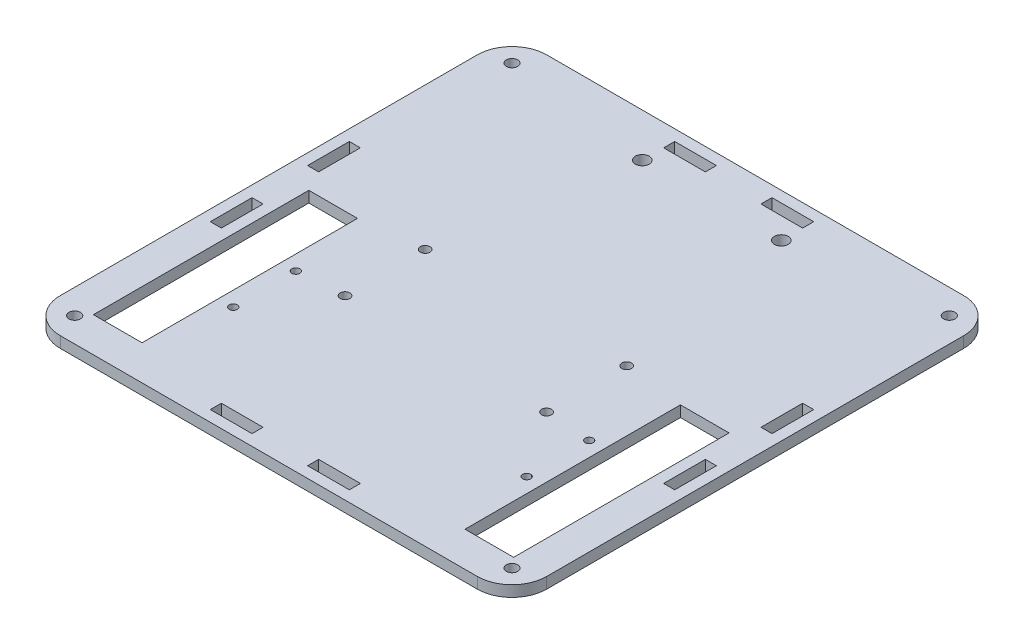
from build123d import *

# Parameters (mm, degrees)
SKETCH1_W           = 140
SKETCH1_H           = 140
SKETCH1_R           = 1.4
SKETCH1_R_2         = 1.15
SKETCH1_R_3         = 2
SKETCH1_R_4         = 1.65
SKETCH1_W_2         = 14
SKETCH1_H_2         = 62
SKETCH1_W_3         = 3.175
SKETCH1_H_3         = 12
SKETCH1_W_4         = 12
SKETCH1_H_4         = 3.175
BOSS_EXTRUDE1_DEPTH = 3.175
FILLET1_R           = 10


with BuildPart() as part:
    # Sketch1 → Boss-Extrude1 (new body)
    with BuildSketch(Plane(origin=(0, 0, 0), x_dir=(1, 0, 0), z_dir=(0, 1, 0))):
        Rectangle(SKETCH1_W, SKETCH1_H)
        with Locations((29, 4)):
            Circle(SKETCH1_R, mode=Mode.SUBTRACT)
        with Locations((29, -19.05)):
            Circle(SKETCH1_R, mode=Mode.SUBTRACT)
        with Locations((-29, -19.05)):
            Circle(SKETCH1_R, mode=Mode.SUBTRACT)
        with Locations((-29, 4)):
            Circle(SKETCH1_R, mode=Mode.SUBTRACT)
        with Locations((42.225, -20)):
            Circle(SKETCH1_R_2, mode=Mode.SUBTRACT)
        with Locations((42.225, -38)):
            Circle(SKETCH1_R_2, mode=Mode.SUBTRACT)
        with Locations((-42.225, -38)):
            Circle(SKETCH1_R_2, mode=Mode.SUBTRACT)
        with Locations((-42.225, -20)):
            Circle(SKETCH1_R_2, mode=Mode.SUBTRACT)
        with Locations((20, 57.5)):
            Circle(SKETCH1_R_3, mode=Mode.SUBTRACT)
        with Locations((-20, 57.5)):
            Circle(SKETCH1_R_3, mode=Mode.SUBTRACT)
        with Locations((62.928932188, -62.928932188)):
            Circle(SKETCH1_R_4, mode=Mode.SUBTRACT)
        with Locations((62.928932188, 62.928932188)):
            Circle(SKETCH1_R_4, mode=Mode.SUBTRACT)
        with Locations((-62.928932188, -62.928932188)):
            Circle(SKETCH1_R_4, mode=Mode.SUBTRACT)
        with Locations((-62.928932188, 62.928932188)):
            Circle(SKETCH1_R_4, mode=Mode.SUBTRACT)
        with Locations((-53.475, -29)):
            Rectangle(SKETCH1_W_2, SKETCH1_H_2, mode=Mode.SUBTRACT)
        with Locations((53.475, -29)):
            Rectangle(SKETCH1_W_2, SKETCH1_H_2, mode=Mode.SUBTRACT)
        with Locations((-65.2375, -14)):
            Rectangle(SKETCH1_W_3, SKETCH1_H_3, mode=Mode.SUBTRACT)
        with Locations((65.2375, -14)):
            Rectangle(SKETCH1_W_3, SKETCH1_H_3, mode=Mode.SUBTRACT)
        with Locations((14, -65.2375)):
            Rectangle(SKETCH1_W_4, SKETCH1_H_4, mode=Mode.SUBTRACT)
        with Locations((-14, -65.2375)):
            Rectangle(SKETCH1_W_4, SKETCH1_H_4, mode=Mode.SUBTRACT)
        with Locations((65.2375, 14)):
            Rectangle(SKETCH1_W_3, SKETCH1_H_3, mode=Mode.SUBTRACT)
        with Locations((14, 65.2375)):
            Rectangle(SKETCH1_W_4, SKETCH1_H_4, mode=Mode.SUBTRACT)
        with Locations((-14, 65.2375)):
            Rectangle(SKETCH1_W_4, SKETCH1_H_4, mode=Mode.SUBTRACT)
        with Locations((-65.2375, 14)):
            Rectangle(SKETCH1_W_3, SKETCH1_H_3, mode=Mode.SUBTRACT)
    extrude(amount=BOSS_EXTRUDE1_DEPTH)

    # Fillet1
    fillet1_edges = [part.edges().sort_by_distance(p)[0] for p in [
        (70, 1.5875, 70),
        (-70, 1.5875, 70),
        (-70, 1.5875, -70),
        (70, 1.5875, -70),
    ]]
    fillet(fillet1_edges, radius=FILLET1_R)


solid = part.part
